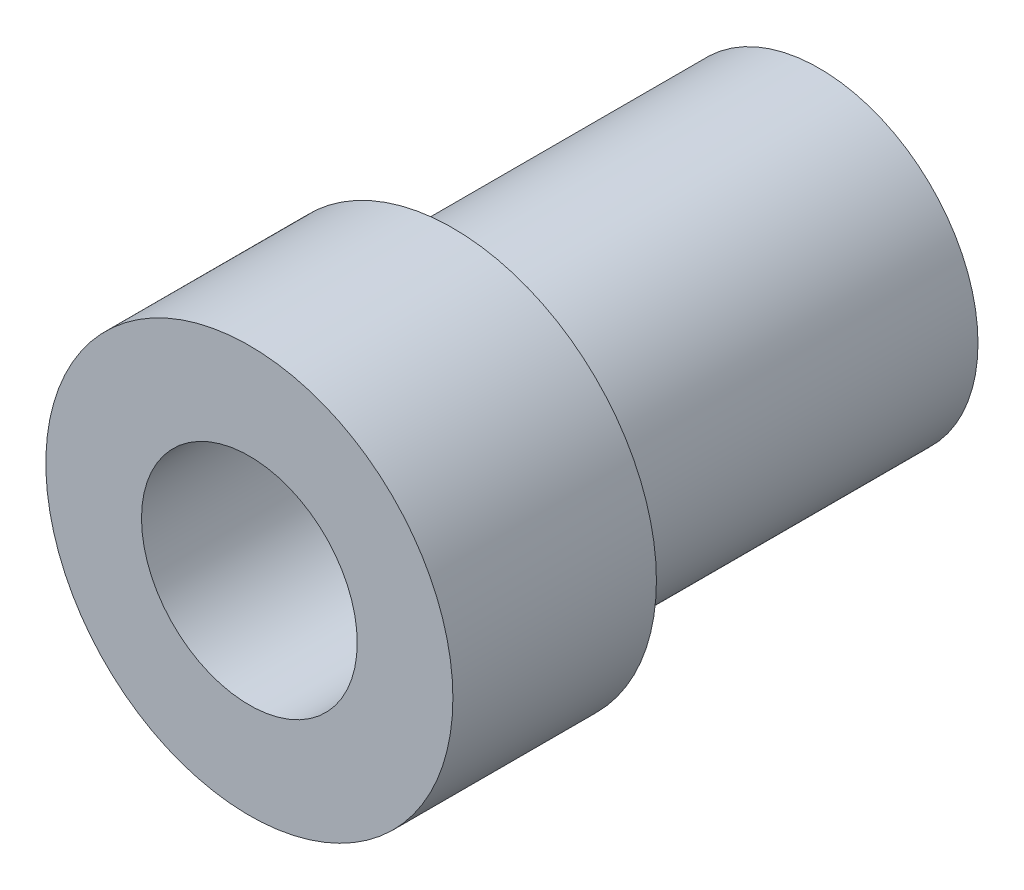
from build123d import *

# Parameters (mm, degrees)
SCHIZZO1_R                   = 3.9
SCHIZZO1_R_2                 = 2.65
ESTRUSIONE_ESTRUSIONE1_DEPTH = 9
SCHIZZO2_R                   = 5
SCHIZZO2_R_2                 = 3.9
ESTRUSIONE_ESTRUSIONE3_DEPTH = 5
SCHIZZO3_R                   = 3.9
SCHIZZO3_R_2                 = 2.65
ESTRUSIONE_ESTRUSIONE4_DEPTH = 5


with BuildPart() as part:
    # Schizzo1 → Estrusione-Estrusione1 (new body)
    with BuildSketch(Plane.XY):
        Circle(SCHIZZO1_R)
        Circle(SCHIZZO1_R_2, mode=Mode.SUBTRACT)
    extrude(amount=ESTRUSIONE_ESTRUSIONE1_DEPTH)



with BuildPart() as body_2:
    # Schizzo2 → Estrusione-Estrusione3 (new body)
    with BuildSketch(Plane.XY.offset(9)):
        Circle(SCHIZZO2_R)
        Circle(SCHIZZO2_R_2, mode=Mode.SUBTRACT)
    extrude(amount=ESTRUSIONE_ESTRUSIONE3_DEPTH)


with BuildPart() as part_1:
    add(part.part)

    add(body_2.part)  # Estrusione-Estrusione4 merges body 2
    # Schizzo3 → Estrusione-Estrusione4 (add)
    with BuildSketch(Plane.XY.offset(9)):
        Circle(SCHIZZO3_R)
        Circle(SCHIZZO3_R_2, mode=Mode.SUBTRACT)
    extrude(amount=ESTRUSIONE_ESTRUSIONE4_DEPTH)


solid = part_1.part
